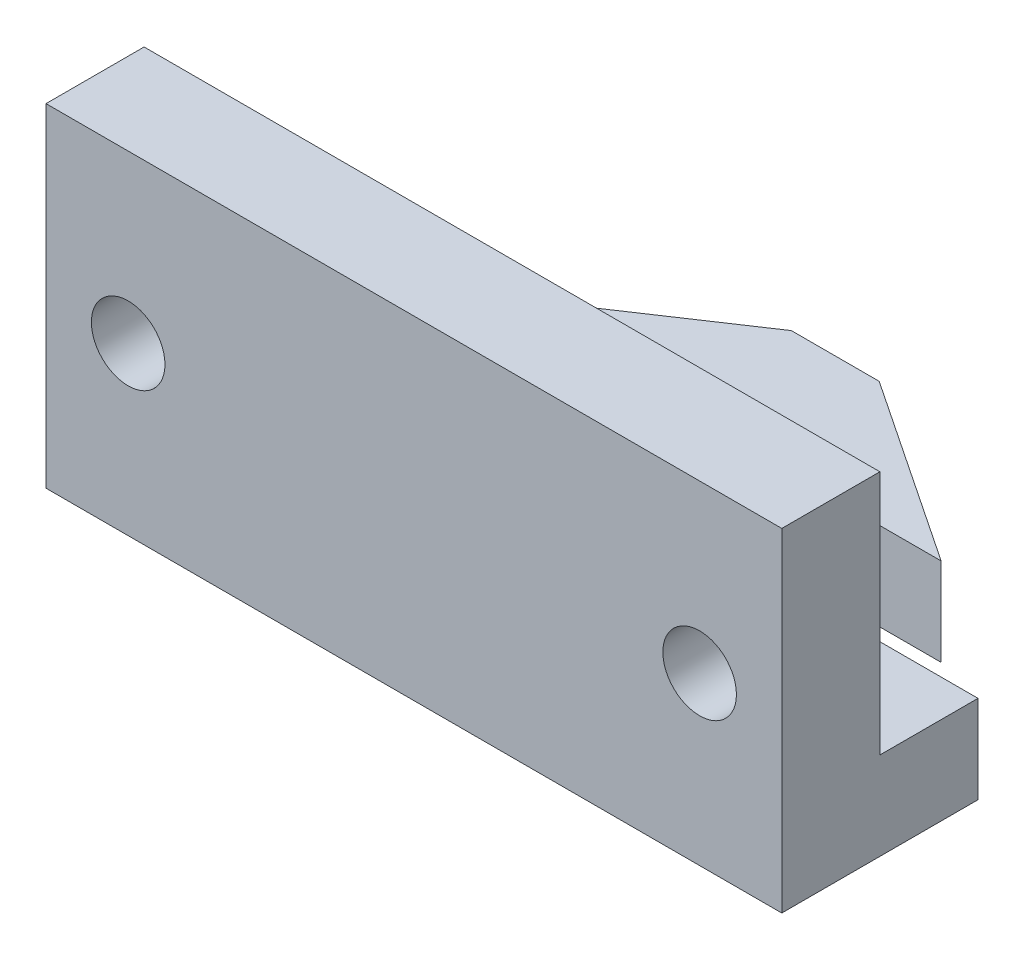
from build123d import *

# Parameters (mm, degrees)
BOSS_EXTRUDE1_DEPTH = 3.5814
SKETCH2_W           = 30
SKETCH2_H           = 4
BOSS_EXTRUDE2_DEPTH = 10
SKETCH3_R           = 1.5
CUT_EXTRUDE1_DEPTH  = 4


with BuildPart() as part:
    # Sketch1 → Boss-Extrude1 (new body)
    with BuildSketch(Plane(origin=(0, 0, 0), x_dir=(1, 0, 0), z_dir=(0, 1, 0))):
        Polygon((-15, -10.05), (15, -10.05), (15, -2.05), (1.7907, -2.05), (1.7907, 2.05), (9.398, 2.05), (1.7907, 7.13), (-1.7907, 7.13), (-9.398, 2.05), (-1.7907, 2.05), (-1.7907, -2.05), (-15, -2.05), align=None)
    extrude(amount=BOSS_EXTRUDE1_DEPTH)

    # Sketch2 → Boss-Extrude2 (add)
    with BuildSketch(Plane(origin=(0, 3.5814, 0), x_dir=(1, 0, 0), z_dir=(0, 1, 0))):
        with Locations((0, -8.05)):
            Rectangle(SKETCH2_W, SKETCH2_H)
    extrude(amount=BOSS_EXTRUDE2_DEPTH)

    # Sketch3 → Cut-Extrude1 (cut)
    with BuildSketch(Plane.XY.offset(10.05)):
        with Locations((-11.65, 6.7907)):
            Circle(SKETCH3_R)
        with Locations((11.65, 6.7907)):
            Circle(SKETCH3_R)
    extrude(amount=-CUT_EXTRUDE1_DEPTH, mode=Mode.SUBTRACT)


solid = part.part
